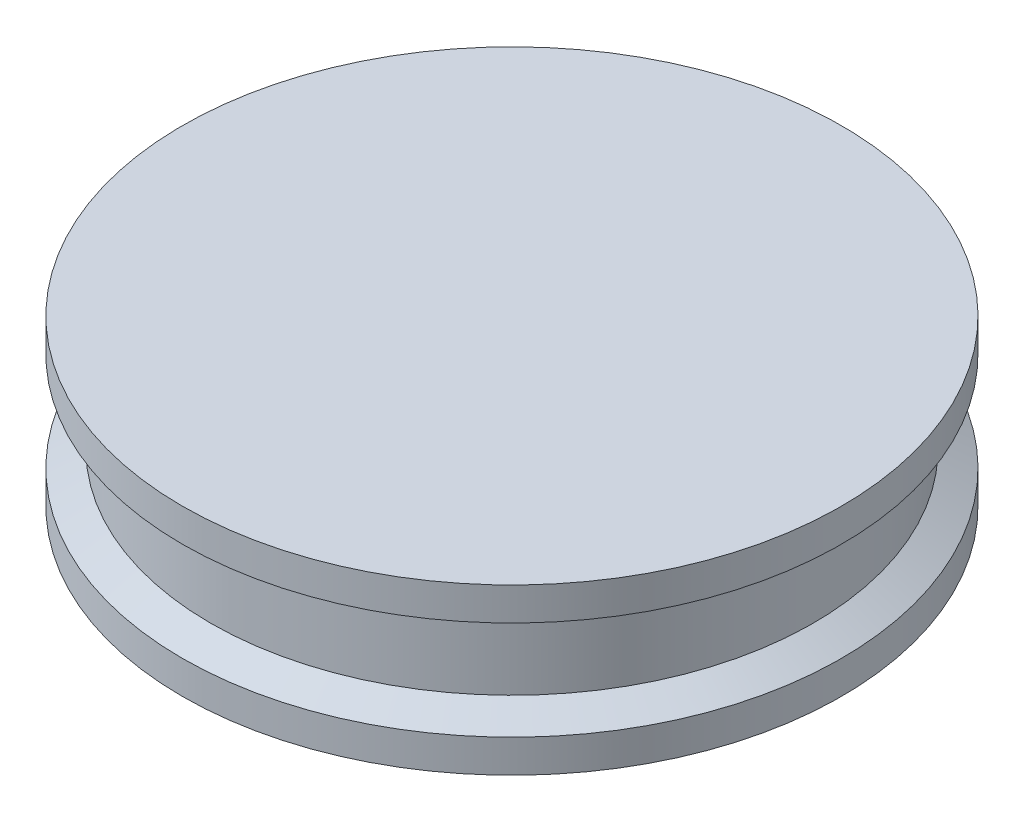
from build123d import *

# Parameters (mm, degrees)
SKETCH2_R           = 20
BOSS_EXTRUDE1_DEPTH = 5


with BuildPart() as part:
    # Sketch2 → Boss-Extrude1 (new body, symmetric)
    with BuildSketch(Plane(origin=(0, 0, 0), x_dir=(1, 0, 0), z_dir=(0, 1, 0))):
        Circle(SKETCH2_R)
    extrude(amount=BOSS_EXTRUDE1_DEPTH, both=True)

    # Sketch3 → Cut-Revolve1 (revolve, cut)
    with BuildSketch(Plane(origin=(0, 0, 0), x_dir=(0, 0, -1), z_dir=(1, 0, 0))):
        Polygon((20, 3), (18.284475438, 2.009541432), (18.284475438, -2.009541432), (20, -3), align=None)
    revolve(axis=Axis((0, 7.747762259, 0), (0, -1, 0)), mode=Mode.SUBTRACT)


solid = part.part
